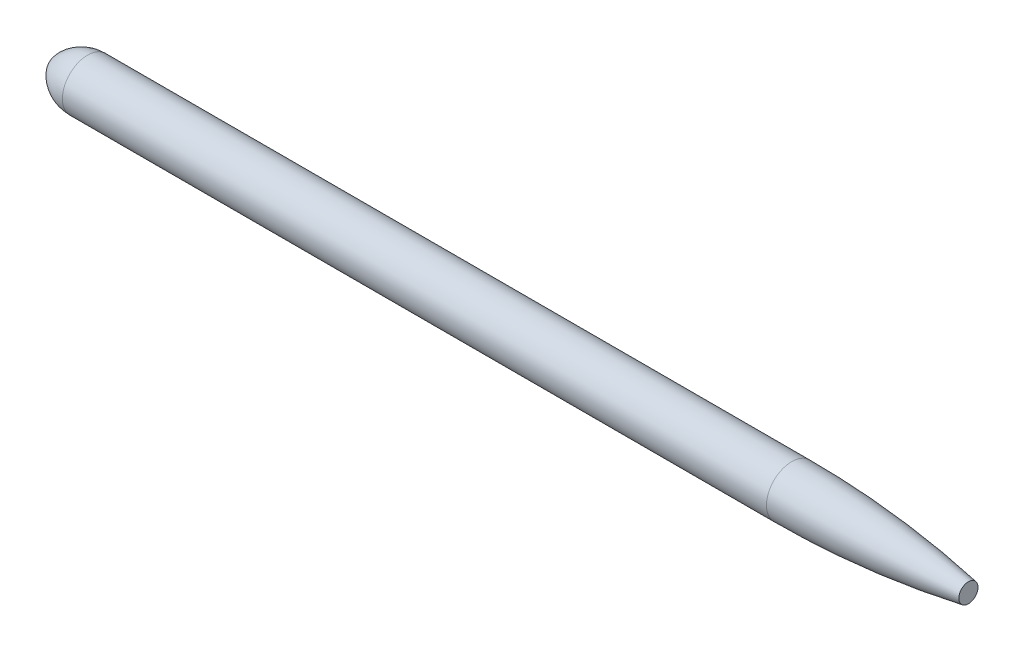
from build123d import *


with BuildPart() as part:
    # Sketch1 → Revolve1 (revolve)
    with BuildSketch(Plane.XY):
        with BuildLine():
            Line((270, 184.169947557), (5410, 184.169947557))
            ThreePointArc((5410, 184.169947557), (6057.52119211, 155.571785687), (6700, 70))
            Line((6700, 70), (6700, 0))
            Line((6700, 0), (0, 0))
            ThreePointArc((0, 0), (106.584448733, 133.743229883), (270, 184.169947557))
        make_face()
    revolve(axis=Axis((6700, 0, 0), (-1, 0, 0)))


solid = part.part
